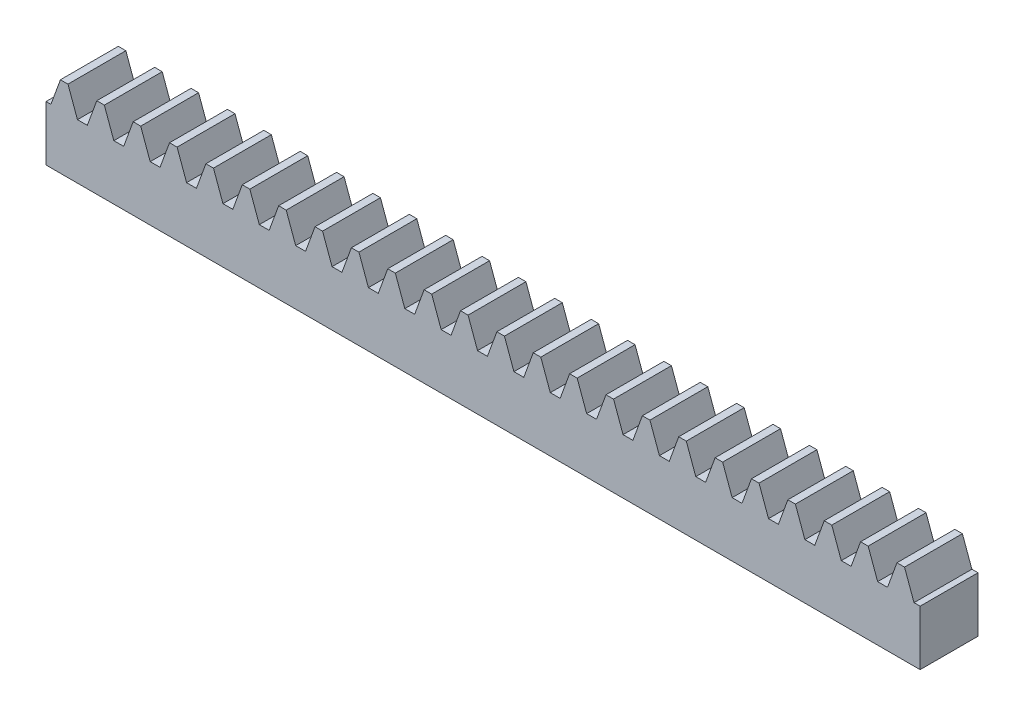
from build123d import *

# Parameters (mm, degrees)
BLANKSKE_W        = 302
BLANKSKE_H        = 28
BLANK_DEPTH       = 20
TOOTHCUTSIM_DEPTH = 304.95394388
TEETHCUTS_COUNT   = 25
TEETHCUTS_PITCH   = 12.5663706


with BuildPart() as part:
    # BlankSke → Blank (new body)
    with BuildSketch(Plane.XY):
        with Locations((151, 14)):
            Rectangle(BLANKSKE_W, BLANKSKE_H)
    extrude(amount=-BLANK_DEPTH)

    # TooCutSkeSim → ToothCutSim (cut, through all)
    with BuildSketch(Plane.XY):
        Polygon((1.702741479, 19), (-1.702741479, 19), (-4.987718431, 28.0254), (4.987718431, 28.0254), align=None)
    toothcutsim = extrude(amount=-TOOTHCUTSIM_DEPTH, mode=Mode.SUBTRACT)

    # TeethCuts: ToothCutSim ×25
    with Locations(*[(i * TEETHCUTS_PITCH, 0, 0) for i in range(1, TEETHCUTS_COUNT)]):
        add(toothcutsim, mode=Mode.SUBTRACT)


solid = part.part
